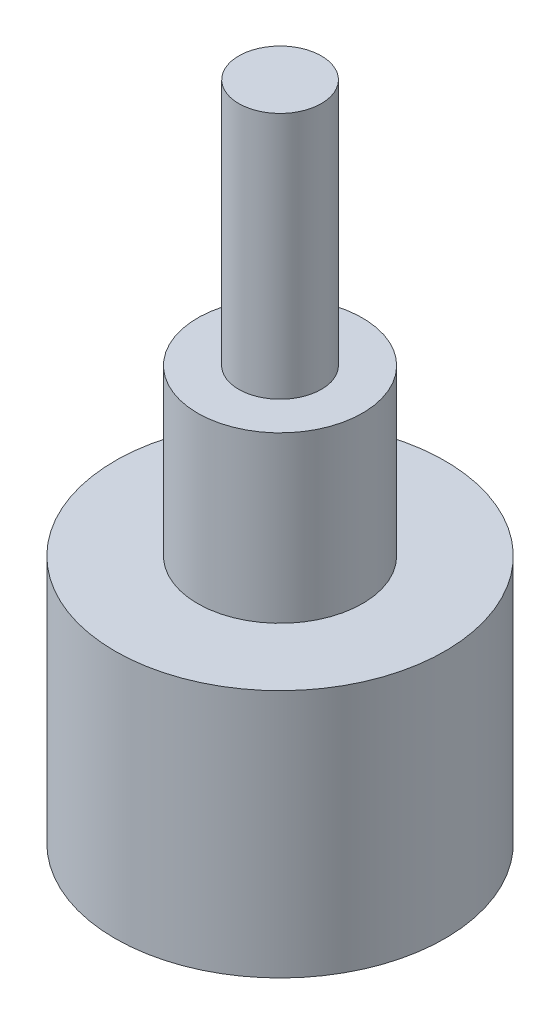
from build123d import *

# Parameters (mm, degrees)
SKETCH1_R           = 6.35
BOSS_EXTRUDE1_DEPTH = 9.58
SKETCH4_R           = 3.175
BOSS_EXTRUDE2_DEPTH = 6.35
SKETCH5_R           = 1.59
BOSS_EXTRUDE3_DEPTH = 9.53


with BuildPart() as part:
    # Sketch1 → Boss-Extrude1 (new body)
    with BuildSketch(Plane(origin=(0, 0, 0), x_dir=(1, 0, 0), z_dir=(0, 1, 0))):
        Circle(SKETCH1_R)
    extrude(amount=BOSS_EXTRUDE1_DEPTH)

    # Sketch4 → Boss-Extrude2 (add)
    with BuildSketch(Plane(origin=(0, 9.58, 0), x_dir=(1, 0, 0), z_dir=(0, 1, 0))):
        Circle(SKETCH4_R)
    extrude(amount=BOSS_EXTRUDE2_DEPTH)

    # Sketch5 → Boss-Extrude3 (add)
    with BuildSketch(Plane(origin=(0, 15.93, 0), x_dir=(1, 0, 0), z_dir=(0, 1, 0))):
        Circle(SKETCH5_R)
    extrude(amount=BOSS_EXTRUDE3_DEPTH)


solid = part.part
